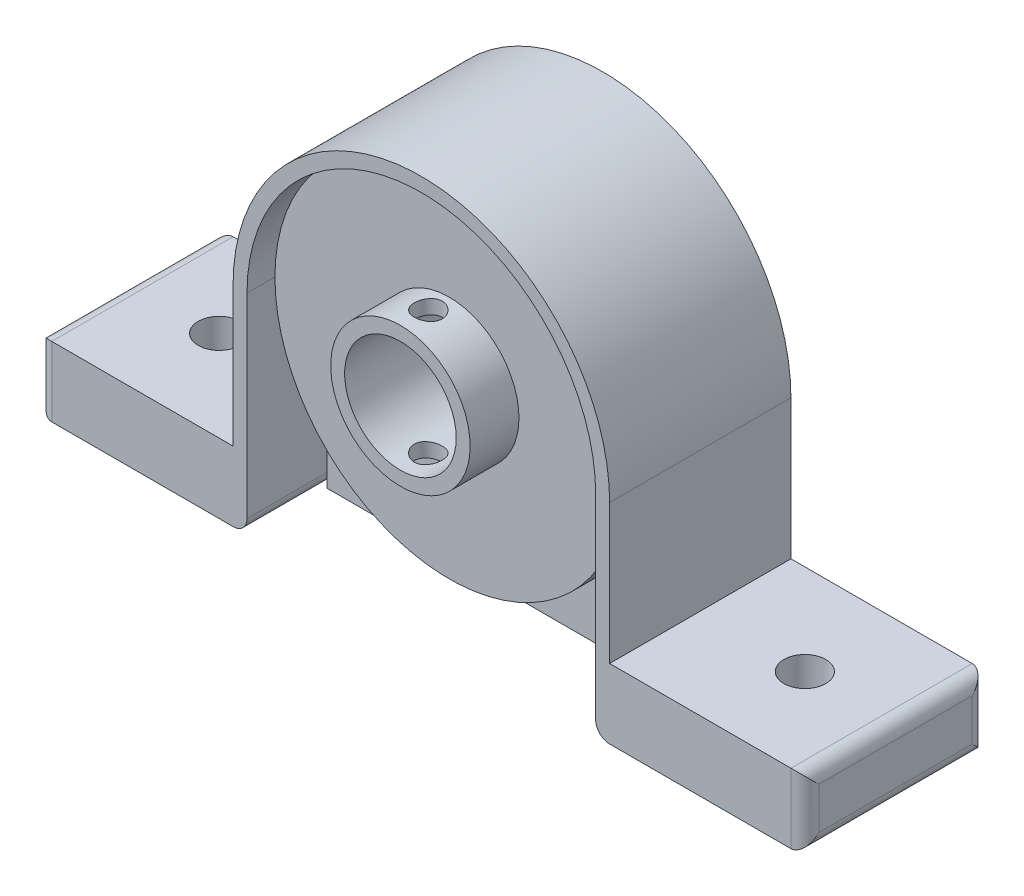
from build123d import *

# Parameters (mm, degrees)
BOSS_EXTRUDE1_DEPTH = 13
SKETCH6_R           = 12.5
SKETCH6_R_2         = 5
CUT_EXTRUDE2_DEPTH  = 2
SKETCH7_R           = 4.5
CUT_EXTRUDE5_DEPTH  = 1.75
SKETCH9_R           = 5
CUT_EXTRUDE6_DEPTH  = 1.75
SKETCH10_R          = 5
BOSS_EXTRUDE4_DEPTH = 3.25
SKETCH11_R          = 4
CUT_EXTRUDE7_DEPTH  = 15.5
FILLET1_R           = 1
FILLET2_R           = 1
SKETCH13_R          = 1
CUT_EXTRUDE11_DEPTH = 10
SKETCH15_R          = 1.5
CUT_EXTRUDE13_DEPTH = 10
BOSS_EXTRUDE5_REACH = 30.5
SKETCH16_W          = 25
SKETCH16_H          = 1.5


with BuildPart() as part:
    # Sketch3 → Boss-Extrude1 (new body)
    with BuildSketch(Plane.XY):
        with BuildLine():
            Line((0, 5), (0, 0))
            Line((0, 0), (15, 0))
            Line((15, 0), (15, 15))
            ThreePointArc((15, 15), (27.5, 2.5), (40, 15))
            Line((40, 15), (40, 0))
            Line((40, 0), (55, 0))
            Line((55, 0), (55, 5))
            Line((55, 5), (41, 5))
            Line((41, 5), (41, 15))
            ThreePointArc((41, 15), (27.5, 28.5), (14, 15))
            Line((14, 15), (14, 5))
            Line((14, 5), (0, 5))
        make_face()
    extrude(amount=BOSS_EXTRUDE1_DEPTH)

    # Sketch6 → Cut-Extrude2 (cut)
    with BuildSketch(Plane.XY.offset(13)):
        with Locations((27.5, 15)):
            Circle(SKETCH6_R)
        with Locations((27.5, 15)):
            Circle(SKETCH6_R_2, mode=Mode.SUBTRACT)
    cut_extrude2 = extrude(amount=-CUT_EXTRUDE2_DEPTH, mode=Mode.SUBTRACT)

    # Mirror1: Cut-Extrude2 across plane
    add(cut_extrude2.mirror(Plane.XY.offset(6.5)), mode=Mode.SUBTRACT)

    # Sketch7 → Cut-Extrude5 (cut)
    with BuildSketch(Plane.XY.offset(13)):
        with Locations((27.5, 15)):
            Circle(SKETCH7_R)
    extrude(amount=-CUT_EXTRUDE5_DEPTH, mode=Mode.SUBTRACT)

    # Sketch9 → Cut-Extrude6 (cut)
    with BuildSketch(Plane(origin=(0, 0, 0), x_dir=(-1, 0, 0), z_dir=(0, 0, -1))):
        with Locations((-27.5, 15)):
            Circle(SKETCH9_R)
    extrude(amount=-CUT_EXTRUDE6_DEPTH, mode=Mode.SUBTRACT)

    # Sketch10 → Boss-Extrude4 (add)
    with BuildSketch(Plane.XY.offset(11.25)):
        with Locations((27.5, 15)):
            Circle(SKETCH10_R)
    extrude(amount=BOSS_EXTRUDE4_DEPTH)

    # Sketch11 → Cut-Extrude7 (cut, through all)
    with BuildSketch(Plane.XY.offset(14.5)):
        with Locations((27.5, 15)):
            Circle(SKETCH11_R)
    extrude(amount=-CUT_EXTRUDE7_DEPTH, mode=Mode.SUBTRACT)

    # Fillet1
    fillet1_edges = [part.edges().sort_by_distance(p)[0] for p in [
        (55, 2.5, 0),
        (0, 2.5, 0),
        (0, 2.5, 13),
        (55, 5, 6.5),
        (55, 0, 6.5),
        (0, 0, 6.5),
        (0, 5, 6.5),
        (55, 2.5, 13),
    ]]
    fillet(fillet1_edges, radius=FILLET1_R)

    # Fillet2
    fillet2_edges = [part.edges().sort_by_distance(p)[0] for p in [
        (40, 0, 6.5),
        (15, 0, 6.5),
    ]]
    fillet(fillet2_edges, radius=FILLET2_R)

    # Sketch13 → Cut-Extrude11 (cut, symmetric)
    with BuildSketch(Plane(origin=(0, 14.25, 0), x_dir=(1, 0, 0), z_dir=(0, 1, 0))):
        with Locations((27.5, -12.5)):
            Circle(SKETCH13_R)
    extrude(amount=CUT_EXTRUDE11_DEPTH, both=True, mode=Mode.SUBTRACT)

    # Sketch15 → Cut-Extrude13 (cut)
    with BuildSketch(Plane(origin=(0, 0, 0), x_dir=(1, 0, 0), z_dir=(0, 1, 0))):
        with Locations((6.5, -6.5)):
            Circle(SKETCH15_R)
    cut_extrude13 = extrude(amount=CUT_EXTRUDE13_DEPTH, mode=Mode.SUBTRACT)

    # Mirror2: Cut-Extrude13 across plane
    add(cut_extrude13.mirror(Plane(origin=(27.5, 0, 0), x_dir=(0, 0, 1), z_dir=(1, 0, 0))), mode=Mode.SUBTRACT)

    # Sketch16 → Boss-Extrude5 (add, up to next)
    with BuildSketch(Plane.XZ, mode=Mode.PRIVATE) as boss_extrude5_sk1:
        with Locations((27.5, 6.5)):
            Rectangle(SKETCH16_W, SKETCH16_H)
    boss_extrude5_tool1 = extrude(boss_extrude5_sk1.sketch, amount=-BOSS_EXTRUDE5_REACH, mode=Mode.PRIVATE) - part.part
    add(boss_extrude5_tool1.solids().sort_by_distance((27.5, 0, 6.5))[0])


solid = part.part
